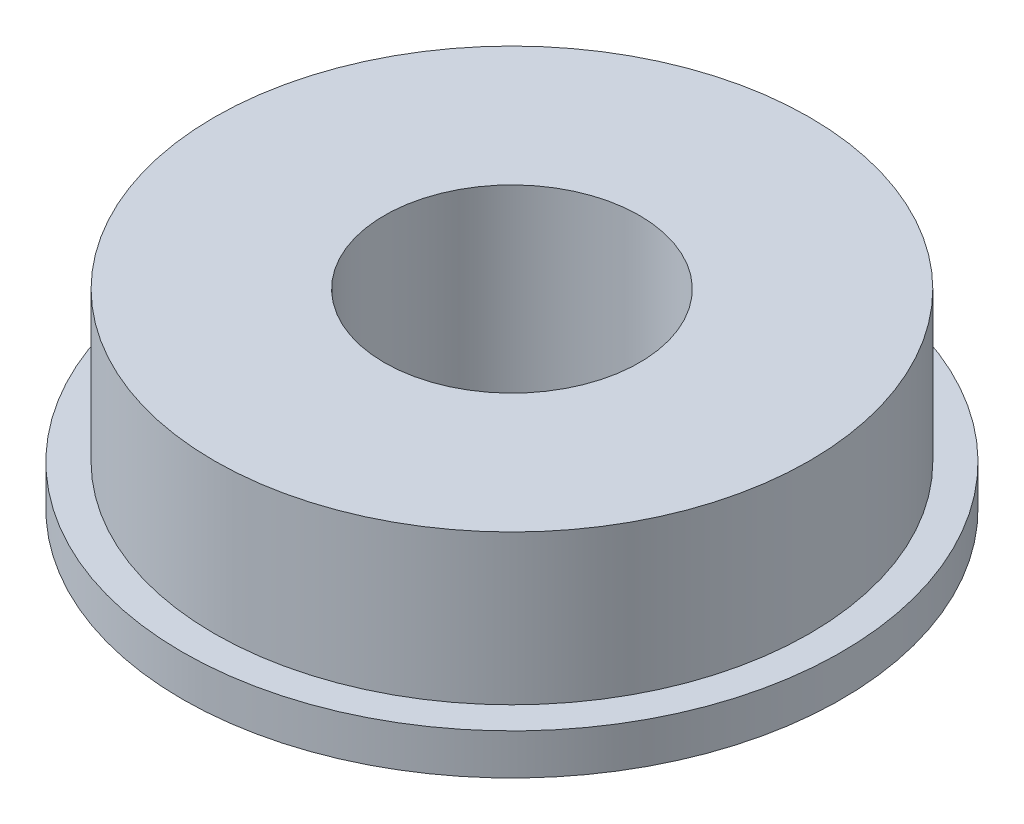
from build123d import *

# Parameters (mm, degrees)
SKETCH_1_R          = 12.3063
EXTRUDE_1_DEPTH     = 1.524
SKETCH_2_R          = 11.1125
EXTRUDE_2_DEPTH     = 5.588
SKETCH_3_R          = 4.7625
CUT_EXTRUDE_1_DEPTH = 8.112


with BuildPart() as part:
    # 草圖1 → 填料-伸長1 (new body)
    with BuildSketch(Plane(origin=(0, 0, 0), x_dir=(1, 0, 0), z_dir=(0, 1, 0))):
        Circle(SKETCH_1_R)
    extrude(amount=EXTRUDE_1_DEPTH)

    # 草圖2 → 填料-伸長2 (add)
    with BuildSketch(Plane(origin=(0, 1.524, 0), x_dir=(1, 0, 0), z_dir=(0, 1, 0))):
        Circle(SKETCH_2_R)
    extrude(amount=EXTRUDE_2_DEPTH)

    # 草圖3 → 除料-伸長1 (cut, through all)
    with BuildSketch(Plane(origin=(0, 7.112, 0), x_dir=(1, 0, 0), z_dir=(0, 1, 0))):
        Circle(SKETCH_3_R)
    extrude(amount=-CUT_EXTRUDE_1_DEPTH, mode=Mode.SUBTRACT)


solid = part.part
